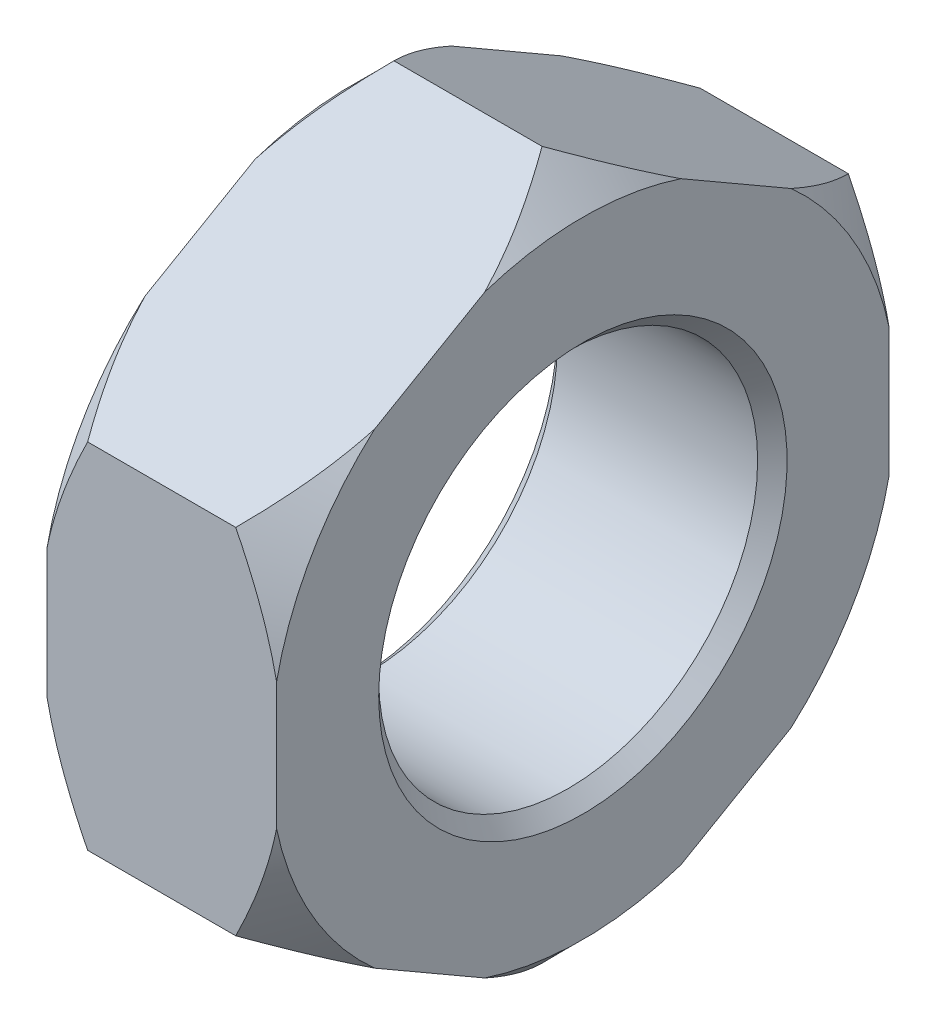
from build123d import *

# Parameters (mm, degrees)
ESBO_O2_R             = 28.575
CORTE_EXTRUS_O1_DEPTH = 10.7188


with BuildPart() as part:
    # Esboço1 → Revolução1 (revolve)
    with BuildSketch(Plane.XY):
        Polygon((0, 0), (0, 14.5923), (3.175, 17.7673), (7.5438, 17.7673), (10.7188, 14.5923), (10.7188, 0), align=None)
    revolve(axis=Axis((10.7188, 0, 0), (-1, 0, 0)))

    # Esboço2 → Corte-extrusão1 (cut)
    with BuildSketch(Plane(origin=(0, 0, 0), x_dir=(0, 0, -1), z_dir=(1, 0, 0))):
        Circle(ESBO_O2_R)
        Polygon((-14.2875, -8.248891971), (0, -16.497783942), (14.2875, -8.248891971), (14.2875, 8.248891971), (0, 16.497783942), (-14.2875, 8.248891971), align=None, mode=Mode.SUBTRACT)
    extrude(amount=CORTE_EXTRUS_O1_DEPTH, mode=Mode.SUBTRACT)

    # Esboço3 → Corte-Revolução1 (revolve, cut)
    with BuildSketch(Plane.XY):
        Polygon((0, 0), (0, 9.525), (0.68707, 8.83793), (10.03173, 8.83793), (10.7188, 9.525), (10.7188, 0), align=None)
    revolve(axis=Axis((10.7188, 0, 0), (-1, 0, 0)), mode=Mode.SUBTRACT)


solid = part.part
